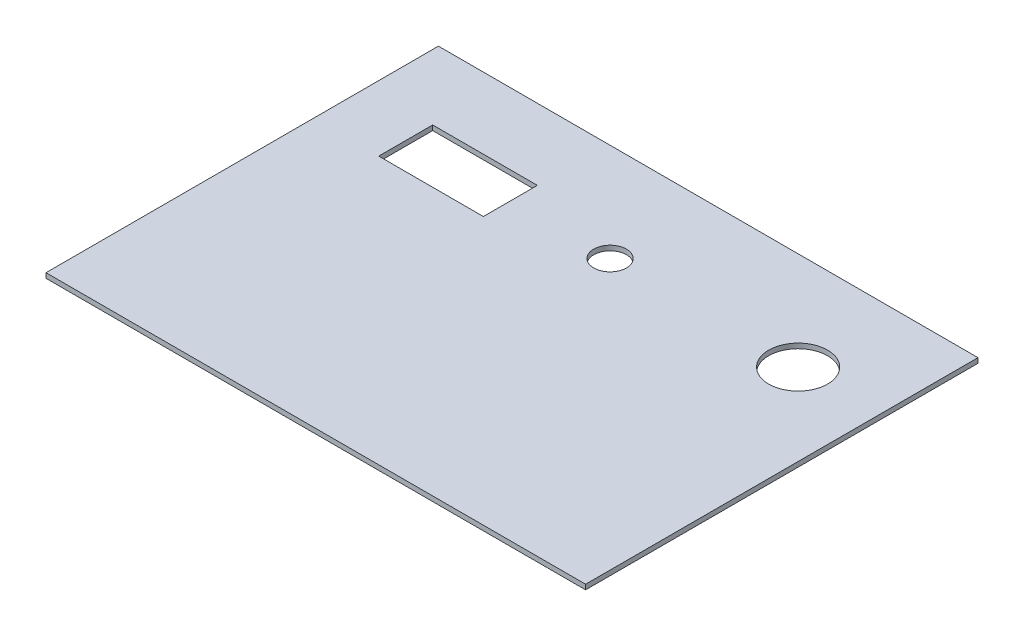
from build123d import *

# Parameters (mm, degrees)
IZIM1_W                     = 330
IZIM1_H                     = 240
IZIM1_R                     = 18
IZIM1_R_2                   = 10
IZIM1_W_2                   = 64
IZIM1_H_2                   = 33
Y_KSEKLIK_EKSTR_ZYON1_DEPTH = 3


with BuildPart() as part:
    # Çizim1 → Yükseklik-Ekstrüzyon1 (new body)
    with BuildSketch(Plane(origin=(0, 0, 0), x_dir=(1, 0, 0), z_dir=(0, 1, 0))):
        with Locations((165, -120)):
            Rectangle(IZIM1_W, IZIM1_H)
        with Locations((280, -60)):
            Circle(IZIM1_R, mode=Mode.SUBTRACT)
        with Locations((165, -60)):
            Circle(IZIM1_R_2, mode=Mode.SUBTRACT)
        with Locations((72, -60)):
            Rectangle(IZIM1_W_2, IZIM1_H_2, mode=Mode.SUBTRACT)
    extrude(amount=Y_KSEKLIK_EKSTR_ZYON1_DEPTH)


solid = part.part
